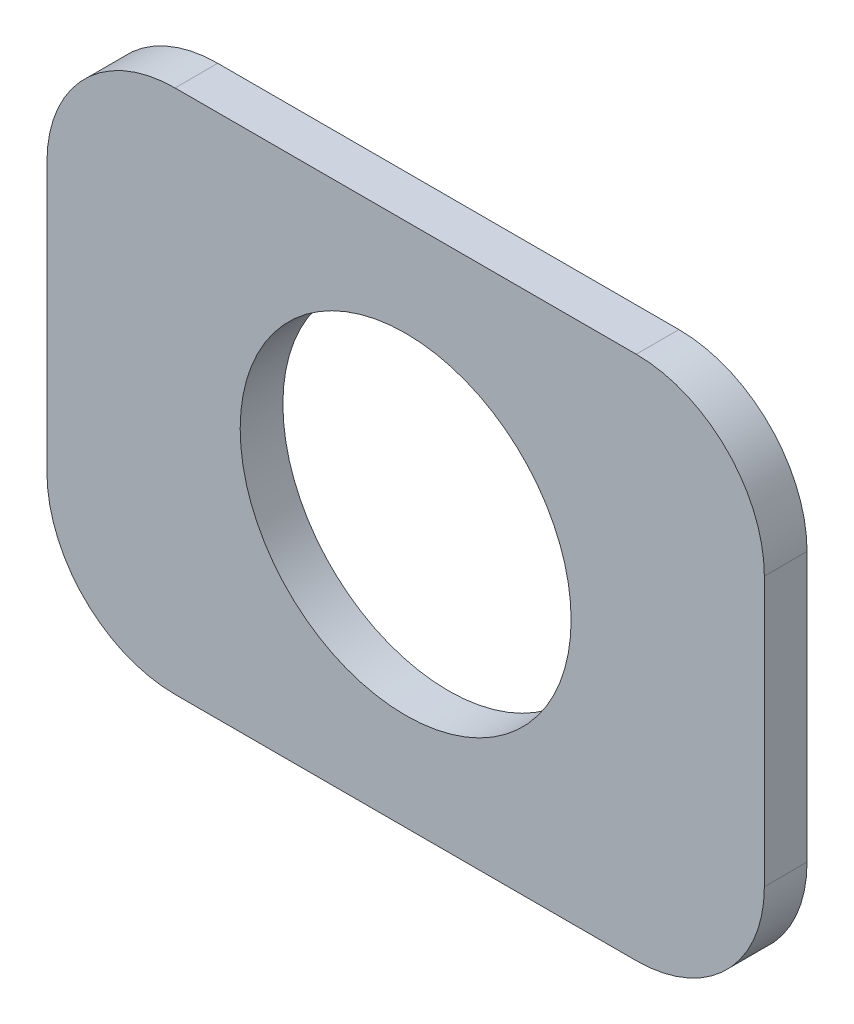
from build123d import *

# Parameters (mm, degrees)
SKETCH1_R           = 1.9685
BOSS_EXTRUDE1_DEPTH = 0.508


with BuildPart() as part:
    # Sketch1 → Boss-Extrude1 (new body)
    with BuildSketch(Plane.XY):
        with BuildLine():
            Line((-4.2672, 1.6002), (-4.2672, -1.6002))
            ThreePointArc((-4.2672, -1.6002), (-3.820830735, -2.677830735), (-2.7432, -3.1242))
            Line((-2.7432, -3.1242), (2.7432, -3.1242))
            ThreePointArc((2.7432, -3.1242), (3.820830735, -2.677830735), (4.2672, -1.6002))
            Line((4.2672, -1.6002), (4.2672, 1.6002))
            ThreePointArc((4.2672, 1.6002), (3.820830735, 2.677830735), (2.7432, 3.1242))
            Line((2.7432, 3.1242), (-2.7432, 3.1242))
            ThreePointArc((-2.7432, 3.1242), (-3.820830735, 2.677830735), (-4.2672, 1.6002))
        make_face()
        Circle(SKETCH1_R, mode=Mode.SUBTRACT)
    extrude(amount=BOSS_EXTRUDE1_DEPTH)


solid = part.part
